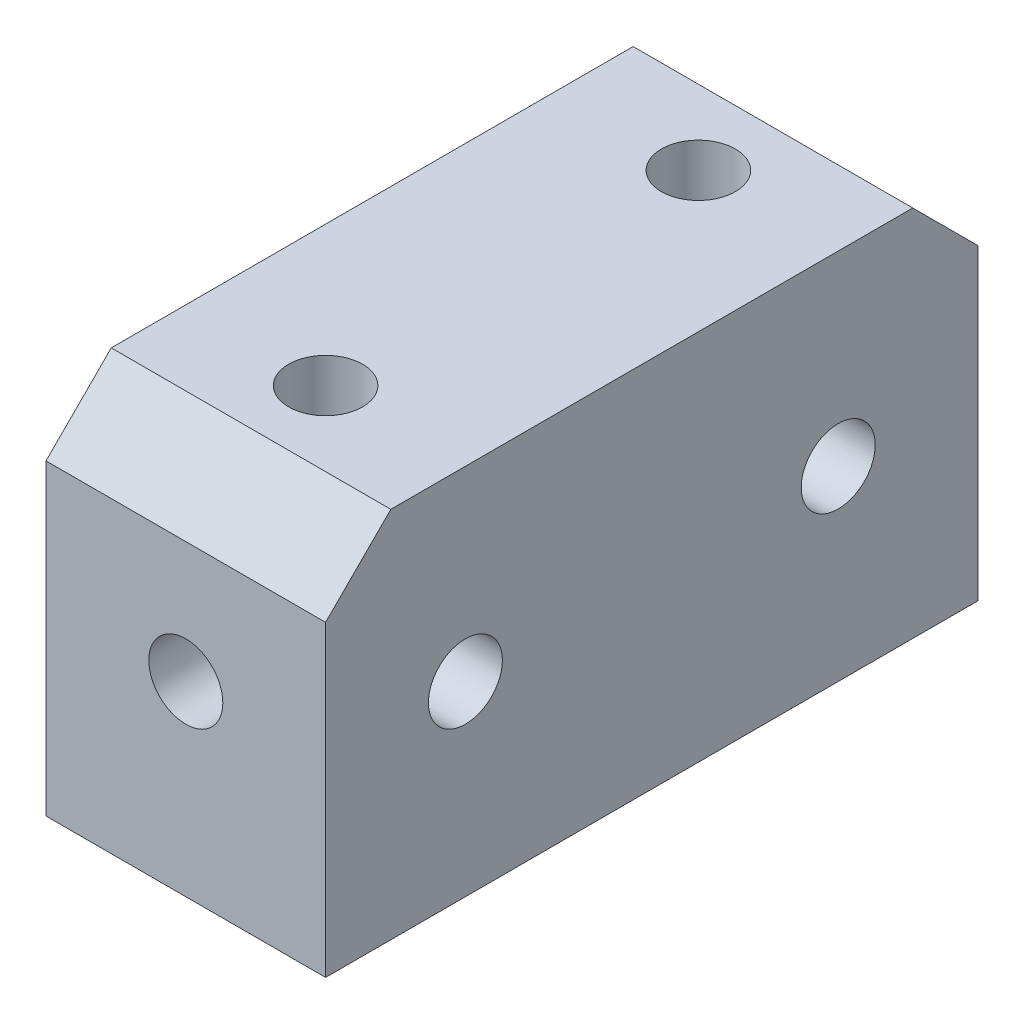
from build123d import *

# Parameters (mm, degrees)
ESBO_O1_W                = 70
ESBO_O1_H                = 40
ESBO_O1_R                = 3.97
RESSALTO_EXTRUS_O1_DEPTH = 15
ESBO_O3_R                = 3.97
CORTE_EXTRUS_O2_DEPTH    = 15
ESBO_O4_R                = 3.97
CORTE_EXTRUS_O3_DEPTH    = 20
CHANFRO2_SIZE            = 7


with BuildPart() as part:
    # Esboço1 → Ressalto-extrusão1 (new body, symmetric)
    with BuildSketch(Plane(origin=(0, 0, 0), x_dir=(0, 0, -1), z_dir=(1, 0, 0))):
        Rectangle(ESBO_O1_W, ESBO_O1_H)
        with Locations((-20, 0)):
            Circle(ESBO_O1_R, mode=Mode.SUBTRACT)
        with Locations((20, 0)):
            Circle(ESBO_O1_R, mode=Mode.SUBTRACT)
    extrude(amount=RESSALTO_EXTRUS_O1_DEPTH, both=True)

    # Esboço3 → Corte-extrusão2 (cut)
    with BuildSketch(Plane.XY.offset(35)):
        Circle(ESBO_O3_R)
    extrude(amount=-CORTE_EXTRUS_O2_DEPTH, mode=Mode.SUBTRACT)

    # Esboço4 → Corte-extrusão3 (cut)
    with BuildSketch(Plane(origin=(0, 20, 0), x_dir=(1, 0, 0), z_dir=(0, 1, 0))):
        with Locations((0, 20)):
            Circle(ESBO_O4_R)
        with Locations((0, -20)):
            Circle(ESBO_O4_R)
    extrude(amount=-CORTE_EXTRUS_O3_DEPTH, mode=Mode.SUBTRACT)

    # Chanfro2
    chanfro2_edges = [part.edges().sort_by_distance(p)[0] for p in [
        (0, 20, 35),
        (0, 20, -35),
    ]]
    chamfer(chanfro2_edges, length=CHANFRO2_SIZE)


solid = part.part
